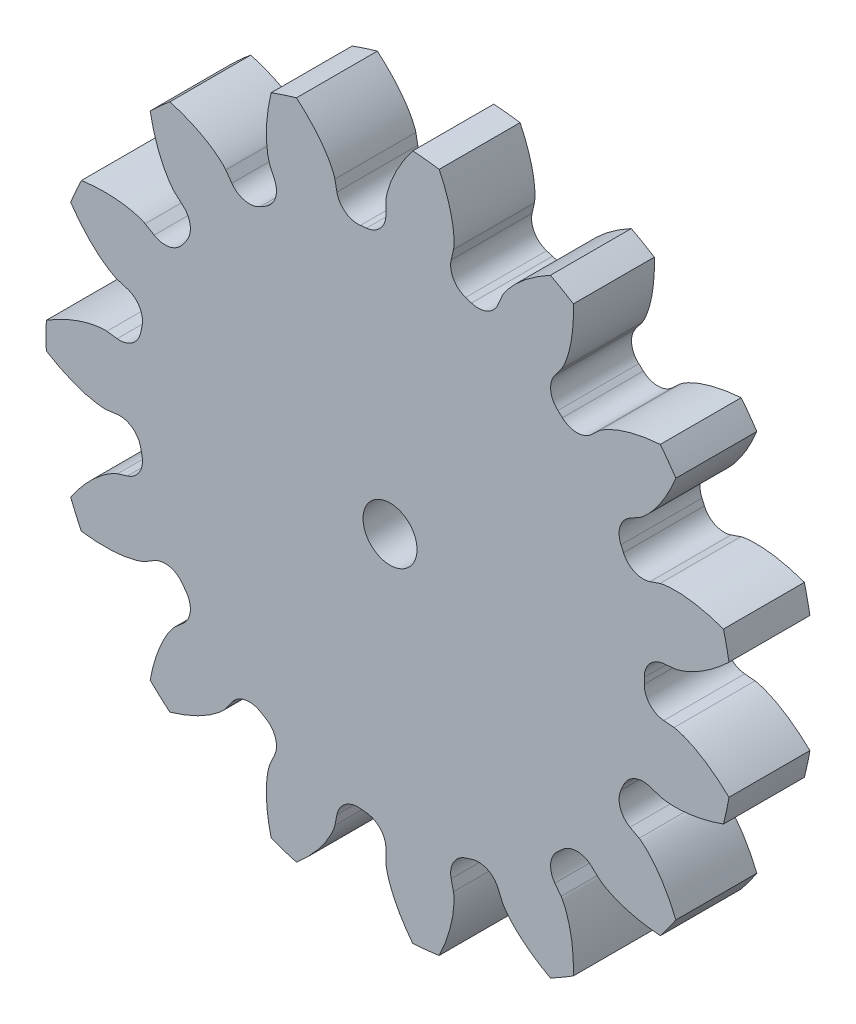
from build123d import *

# Parameters (mm, degrees)
MODEL_R             = 2
BOSS_EXTRUDE3_DEPTH = 6


with BuildPart() as part:
    # Model → Boss-Extrude3 (new body)
    with BuildSketch(Plane.XY):
        with BuildLine():
            Line((-34.011258768, -11.618815397), (-34.774792641, -11.52743848))
            add(Edge.make_bspline(
                [(-34.774792641, -11.52743848), (-34.826134068, -11.521294128), (-34.890522194, -11.517386718), (-34.98103557, -11.518522806), (-35.097797356, -11.525964466), (-35.22773254, -11.536534735), (-35.357743548, -11.548439428), (-35.487878218, -11.564166174), (-35.644167306, -11.588693193), (-35.800499834, -11.617905894), (-35.982808164, -11.655902449), (-36.165028966, -11.698423954), (-36.360077219, -11.750386243), (-36.554881321, -11.806727385), (-36.801193414, -11.884582564), (-37.072735095, -11.979550611), (-37.356271095, -12.087946096), (-37.677019341, -12.222896534), (-38.008768038, -12.375215547), (-38.338592372, -12.538653722), (-38.653580645, -12.706517168), (-38.903824264, -12.848770966), (-39.090405836, -12.959747274), (-39.214314242, -13.035631984), (-39.263800657, -13.066289626)],
                knots=[0, 0, 0, 0, 0, 0, 0.057142857, 0.071428571, 0.1, 0.128571429, 0.142857143, 0.2, 0.214285714, 0.271428571, 0.3, 0.342857143, 0.4, 0.428571429, 0.485714286, 0.571428571, 0.642857143, 0.714285714, 0.785714286, 0.857142857, 0.942857143, 1, 1, 1, 1, 1, 1], degree=5, weights=[1, 1, 1, 1, 1, 1, 1, 1, 1, 1, 1, 1, 1, 1, 1, 1, 1, 1, 1, 1, 1, 1, 1, 1, 1]))
            ThreePointArc((-39.263800657, -13.066289626), (-39.282806436, -14.05063384), (-39.263800657, -15.034978055))
            add(Edge.make_bspline(
                [(-39.263800657, -15.034978055), (-39.102969809, -15.134615388), (-38.89158971, -15.260714719), (-38.62871045, -15.409722251), (-38.300874819, -15.583322699), (-37.906799968, -15.773592135), (-37.625713024, -15.900087405), (-37.317653263, -16.028502931), (-37.008217005, -16.145622994), (-36.73647134, -16.238541398), (-36.490008627, -16.314318325), (-36.269072006, -16.375541947), (-36.086939526, -16.421354833), (-35.943744941, -16.453632457), (-35.787467208, -16.48560511), (-35.657197884, -16.509828379), (-35.52695002, -16.531040649), (-35.396771915, -16.548611412), (-35.266722111, -16.5614978), (-35.123762674, -16.573369014), (-34.993966184, -16.582579543), (-34.890522194, -16.583880962), (-34.826134068, -16.579973552), (-34.774792641, -16.5738292)],
                knots=[-1, -1, -1, -1, -1, -1, -0.814285714, -0.757142857, -0.7, -0.628571429, -0.557142857, -0.5, -0.414285714, -0.357142857, -0.328571429, -0.285714286, -0.257142857, -0.214285714, -0.2, -0.157142857, -0.142857143, -0.114285714, -0.071428571, -0.057142857, 0, 0, 0, 0, 0, 0], degree=5, weights=[1, 1, 1, 1, 1, 1, 1, 1, 1, 1, 1, 1, 1, 1, 1, 1, 1, 1, 1, 1, 1, 1, 1, 1]))
            Line((-34.774792641, -16.5738292), (-34.011258768, -16.482452284))
            ThreePointArc((-34.011258768, -16.482452284), (-32.891020179, -16.773293938), (-32.265948509, -17.747362092))
            ThreePointArc((-32.265948509, -17.747362092), (-32.220106192, -17.969602883), (-32.171591759, -18.191275698))
            ThreePointArc((-32.171591759, -18.191275698), (-32.346433933, -19.335370788), (-33.251526849, -20.056709943))
            Line((-33.251526849, -20.056709943), (-33.986216091, -20.283790181))
            add(Edge.make_bspline(
                [(-33.986216091, -20.283790181), (-34.035617951, -20.299059475), (-34.096028719, -20.321678889), (-34.178254713, -20.359531864), (-34.281895117, -20.413821456), (-34.396297498, -20.476327278), (-34.510226389, -20.540082996), (-34.622713682, -20.607380633), (-34.755514831, -20.693355678), (-34.886449826, -20.783628976), (-35.037542182, -20.892492034), (-35.186714113, -21.00545324), (-35.343764592, -21.132256424), (-35.498810987, -21.262960585), (-35.692161727, -21.434268984), (-35.901600411, -21.631472564), (-36.11653502, -21.845821248), (-36.354663835, -22.099564672), (-36.595777626, -22.373649366), (-36.830610855, -22.657109211), (-37.050090746, -22.938577372), (-37.220839835, -23.170315933), (-37.346152452, -23.347587397), (-37.428483321, -23.467309619), (-37.461221824, -23.515444706)],
                knots=[0, 0, 0, 0, 0, 0, 0.057142857, 0.071428571, 0.1, 0.128571429, 0.142857143, 0.2, 0.214285714, 0.271428571, 0.3, 0.342857143, 0.4, 0.428571429, 0.485714286, 0.571428571, 0.642857143, 0.714285714, 0.785714286, 0.857142857, 0.942857143, 1, 1, 1, 1, 1, 1], degree=5, weights=[1, 1, 1, 1, 1, 1, 1, 1, 1, 1, 1, 1, 1, 1, 1, 1, 1, 1, 1, 1, 1, 1, 1, 1, 1]))
            ThreePointArc((-37.461221824, -23.515444706), (-37.078215606, -24.422418239), (-36.660484101, -25.313931078))
            add(Edge.make_bspline(
                [(-36.660484101, -25.313931078), (-36.473031656, -25.339538512), (-36.228637108, -25.36875995), (-35.927878131, -25.397962477), (-35.557775717, -25.423211614), (-35.120380875, -25.43674671), (-34.812144911, -25.43797753), (-34.478487016, -25.429991758), (-34.148165908, -25.411127194), (-33.86212057, -25.38548346), (-33.606144425, -25.354463711), (-33.379406888, -25.320531254), (-33.194386808, -25.288303454), (-33.050443553, -25.259548046), (-32.894672291, -25.225192637), (-32.76581285, -25.194336387), (-32.638197699, -25.160738181), (-32.512127409, -25.123841666), (-32.388079635, -25.082717948), (-32.252651233, -25.035416), (-32.13032998, -24.991037247), (-32.035299858, -24.950151692), (-31.978067664, -24.920393085), (-31.93366407, -24.893897501)],
                knots=[-1, -1, -1, -1, -1, -1, -0.814285714, -0.757142857, -0.7, -0.628571429, -0.557142857, -0.5, -0.414285714, -0.357142857, -0.328571429, -0.285714286, -0.257142857, -0.214285714, -0.2, -0.157142857, -0.142857143, -0.114285714, -0.071428571, -0.057142857, 0, 0, 0, 0, 0, 0], degree=5, weights=[1, 1, 1, 1, 1, 1, 1, 1, 1, 1, 1, 1, 1, 1, 1, 1, 1, 1, 1, 1, 1, 1, 1, 1]))
            Line((-31.93366407, -24.893897501), (-31.273307508, -24.499863329))
            ThreePointArc((-31.273307508, -24.499863329), (-30.131622677, -24.309918318), (-29.16440208, -24.945534303))
            ThreePointArc((-29.16440208, -24.945534303), (-29.032129567, -25.129915618), (-28.89764697, -25.312691213))
            ThreePointArc((-28.89764697, -25.312691213), (-28.592027848, -26.428988805), (-29.125476303, -27.456099368))
            Line((-29.125476303, -27.456099368), (-29.70428647, -27.962372524))
            add(Edge.make_bspline(
                [(-29.70428647, -27.962372524), (-29.743206733, -27.996415265), (-29.789194571, -28.041650401), (-29.848915562, -28.109675139), (-29.921514216, -28.201425498), (-30.000602584, -28.305059049), (-30.078750018, -28.409641851), (-30.154139858, -28.516874004), (-30.240490543, -28.64943121), (-30.323388155, -28.785156032), (-30.417139296, -28.946062182), (-30.507469174, -29.109931069), (-30.599366424, -29.289649726), (-30.687846183, -29.472116969), (-30.79480347, -29.70725781), (-30.905925306, -29.972598631), (-31.015094378, -30.25583768), (-31.129429127, -30.584499547), (-31.238217247, -30.932958188), (-31.33745457, -31.287426921), (-31.423476013, -31.633831395), (-31.485206504, -31.914985016), (-31.527582475, -32.12789979), (-31.554100052, -32.270758463), (-31.564429859, -32.328048002)],
                knots=[0, 0, 0, 0, 0, 0, 0.057142857, 0.071428571, 0.1, 0.128571429, 0.142857143, 0.2, 0.214285714, 0.271428571, 0.3, 0.342857143, 0.4, 0.428571429, 0.485714286, 0.571428571, 0.642857143, 0.714285714, 0.785714286, 0.857142857, 0.942857143, 1, 1, 1, 1, 1, 1], degree=5, weights=[1, 1, 1, 1, 1, 1, 1, 1, 1, 1, 1, 1, 1, 1, 1, 1, 1, 1, 1, 1, 1, 1, 1, 1, 1]))
            ThreePointArc((-31.564429859, -32.328048002), (-30.845636898, -33.00082689), (-30.10140924, -33.645357684))
            add(Edge.make_bspline(
                [(-30.10140924, -33.645357684), (-29.919747428, -33.592507461), (-29.68459647, -33.519798356), (-29.397961734, -33.424146495), (-29.049586606, -33.296678515), (-28.644501315, -33.131138931), (-28.362413131, -33.00689248), (-28.060849583, -32.863886222), (-27.766759144, -32.712298887), (-27.515873972, -32.57252705), (-27.294644996, -32.440074221), (-27.101311522, -32.316852914), (-26.945395496, -32.212156908), (-26.825592668, -32.127340539), (-26.697262142, -32.032597431), (-26.592093553, -31.951996988), (-26.489176932, -31.869397741), (-26.389013156, -31.784413691), (-26.292416399, -31.696390529), (-26.187935833, -31.598094356), (-26.094240273, -31.507799812), (-26.02405559, -31.431796766), (-25.983875295, -31.381332496), (-25.954087319, -31.339067006)],
                knots=[-1, -1, -1, -1, -1, -1, -0.814285714, -0.757142857, -0.7, -0.628571429, -0.557142857, -0.5, -0.414285714, -0.357142857, -0.328571429, -0.285714286, -0.257142857, -0.214285714, -0.2, -0.157142857, -0.142857143, -0.114285714, -0.071428571, -0.057142857, 0, 0, 0, 0, 0, 0], degree=5, weights=[1, 1, 1, 1, 1, 1, 1, 1, 1, 1, 1, 1, 1, 1, 1, 1, 1, 1, 1, 1, 1, 1, 1, 1]))
            Line((-25.954087319, -31.339067006), (-25.511089717, -30.710507667))
            ThreePointArc((-25.511089717, -30.710507667), (-24.545366321, -30.07261921), (-23.403238027, -30.259879247))
            ThreePointArc((-23.403238027, -30.259879247), (-23.207406436, -30.374519881), (-23.010208939, -30.486794696))
            ThreePointArc((-23.010208939, -30.486794696), (-22.276972843, -31.382276795), (-22.346538754, -32.537562018))
            Line((-22.346538754, -32.537562018), (-22.669388308, -33.235488864))
            add(Edge.make_bspline(
                [(-22.669388308, -33.235488864), (-22.691097308, -33.282418753), (-22.714710501, -33.342448044), (-22.741600188, -33.42888245), (-22.770604125, -33.542229108), (-22.800703382, -33.669071204), (-22.829556957, -33.796397772), (-22.854813757, -33.92502303), (-22.87978316, -34.081242051), (-22.900309639, -34.238950342), (-22.92050914, -34.424077448), (-22.936378109, -34.610519597), (-22.947232261, -34.812078739), (-22.953846429, -35.014758821), (-22.955916376, -35.273074115), (-22.94950739, -35.56067234), (-22.9340346, -35.863827148), (-22.904805766, -36.210578836), (-22.862457761, -36.57315976), (-22.808940145, -36.937346516), (-22.74662925, -37.288790822), (-22.688667379, -37.570745488), (-22.640779515, -37.782488674), (-22.60689867, -37.923782235), (-22.593033664, -37.980320345)],
                knots=[0, 0, 0, 0, 0, 0, 0.057142857, 0.071428571, 0.1, 0.128571429, 0.142857143, 0.2, 0.214285714, 0.271428571, 0.3, 0.342857143, 0.4, 0.428571429, 0.485714286, 0.571428571, 0.642857143, 0.714285714, 0.785714286, 0.857142857, 0.942857143, 1, 1, 1, 1, 1, 1], degree=5, weights=[1, 1, 1, 1, 1, 1, 1, 1, 1, 1, 1, 1, 1, 1, 1, 1, 1, 1, 1, 1, 1, 1, 1, 1, 1]))
            ThreePointArc((-22.593033664, -37.980320345), (-21.662739793, -38.302575006), (-20.720699704, -38.588678526))
            add(Edge.make_bspline(
                [(-20.720699704, -38.588678526), (-20.576239504, -38.466508929), (-20.390991871, -38.304441345), (-20.168043127, -38.100474172), (-19.901632509, -37.842329447), (-19.598899697, -37.526338481), (-19.391734902, -37.298098099), (-19.174408778, -37.044798436), (-18.967399917, -36.786699157), (-18.795055235, -36.556967037), (-18.646825928, -36.345983426), (-18.520325633, -36.154779353), (-18.420472957, -35.995718031), (-18.345525553, -35.869506222), (-18.266825277, -35.730757359), (-18.203532144, -35.614349271), (-18.143109273, -35.497031144), (-18.086171238, -35.378654073), (-18.033727955, -35.258951473), (-17.978260864, -35.126657375), (-17.929391809, -35.006059787), (-17.896188135, -34.908080868), (-17.880007277, -34.845636664), (-17.86998553, -34.794909357)],
                knots=[-1, -1, -1, -1, -1, -1, -0.814285714, -0.757142857, -0.7, -0.628571429, -0.557142857, -0.5, -0.414285714, -0.357142857, -0.328571429, -0.285714286, -0.257142857, -0.214285714, -0.2, -0.157142857, -0.142857143, -0.114285714, -0.071428571, -0.057142857, 0, 0, 0, 0, 0, 0], degree=5, weights=[1, 1, 1, 1, 1, 1, 1, 1, 1, 1, 1, 1, 1, 1, 1, 1, 1, 1, 1, 1, 1, 1, 1, 1]))
            Line((-17.86998553, -34.794909357), (-17.720945199, -34.040508471))
            ThreePointArc((-17.720945199, -34.040508471), (-17.098165587, -33.064973276), (-15.978613953, -32.771498403))
            ThreePointArc((-15.978613953, -32.771498403), (-15.753084346, -32.79657595), (-15.527269187, -32.81893665))
            ThreePointArc((-15.527269187, -32.81893665), (-14.493199299, -33.338766265), (-14.086854087, -34.422466838))
            Line((-14.086854087, -34.422466838), (-14.097919409, -35.191369482))
            add(Edge.make_bspline(
                [(-14.097919409, -35.191369482), (-14.098663462, -35.243071914), (-14.095819074, -35.307515751), (-14.085227985, -35.397414531), (-14.065622162, -35.51275882), (-14.041527872, -35.640877311), (-14.016098544, -35.768931726), (-13.986855174, -35.896709612), (-13.946125858, -36.04957876), (-13.900731989, -36.202001324), (-13.843887174, -36.379339228), (-13.782551345, -36.556117097), (-13.710485617, -36.744665318), (-13.634090544, -36.93251301), (-13.530915239, -37.169337697), (-13.408083603, -37.42946498), (-13.270644337, -37.700117327), (-13.10290585, -38.005002318), (-12.916744075, -38.319011989), (-12.719725201, -38.62994557), (-12.519856089, -38.925661796), (-12.352223991, -39.159664983), (-12.222352537, -39.333624259), (-12.133931576, -39.448921769), (-12.098269142, -39.494932496)],
                knots=[0, 0, 0, 0, 0, 0, 0.057142857, 0.071428571, 0.1, 0.128571429, 0.142857143, 0.2, 0.214285714, 0.271428571, 0.3, 0.342857143, 0.4, 0.428571429, 0.485714286, 0.571428571, 0.642857143, 0.714285714, 0.785714286, 0.857142857, 0.942857143, 1, 1, 1, 1, 1, 1], degree=5, weights=[1, 1, 1, 1, 1, 1, 1, 1, 1, 1, 1, 1, 1, 1, 1, 1, 1, 1, 1, 1, 1, 1, 1, 1, 1]))
            ThreePointArc((-12.098269142, -39.494932496), (-11.117330623, -39.410942172), (-10.140365394, -39.28914852))
            add(Edge.make_bspline(
                [(-10.140365394, -39.28914852), (-10.058085285, -39.118783783), (-9.954771977, -38.895380677), (-9.834059089, -38.618365969), (-9.695677797, -38.274180068), (-9.547642716, -37.862375428), (-9.451221986, -37.569605951), (-9.355710947, -37.249810697), (-9.271577377, -36.929827183), (-9.207573147, -36.649857551), (-9.157973702, -36.396824141), (-9.120179635, -36.170698223), (-9.093655745, -35.984774733), (-9.076522851, -35.838990652), (-9.061060819, -35.680226973), (-9.050587099, -35.548139256), (-9.043105641, -35.416387618), (-9.039238451, -35.285085998), (-9.040016561, -35.154401626), (-9.043153709, -35.010984456), (-9.047561065, -34.880936242), (-9.057079616, -34.777922894), (-9.067696012, -34.714295928), (-9.079173346, -34.663878015)],
                knots=[-1, -1, -1, -1, -1, -1, -0.814285714, -0.757142857, -0.7, -0.628571429, -0.557142857, -0.5, -0.414285714, -0.357142857, -0.328571429, -0.285714286, -0.257142857, -0.214285714, -0.2, -0.157142857, -0.142857143, -0.114285714, -0.071428571, -0.057142857, 0, 0, 0, 0, 0, 0], degree=5, weights=[1, 1, 1, 1, 1, 1, 1, 1, 1, 1, 1, 1, 1, 1, 1, 1, 1, 1, 1, 1, 1, 1, 1, 1]))
            Line((-9.079173346, -34.663878015), (-9.249860712, -33.914078348))
            ThreePointArc((-9.249860712, -33.914078348), (-9.077709137, -32.769575313), (-8.174314811, -32.046110003))
            ThreePointArc((-8.174314811, -32.046110003), (-7.958083306, -31.977288327), (-7.742695977, -31.905868543))
            ThreePointArc((-7.742695977, -31.905868543), (-6.586592375, -31.960162412), (-5.77459682, -32.78489666))
            Line((-5.77459682, -32.78489666), (-5.471964614, -33.49182485))
            add(Edge.make_bspline(
                [(-5.471964614, -33.49182485), (-5.451615066, -33.539360005), (-5.422804919, -33.597075463), (-5.37656435, -33.674894302), (-5.31173879, -33.772292145), (-5.237617076, -33.879534181), (-5.162301806, -33.98617467), (-5.08361471, -34.091011227), (-4.984229145, -34.214098038), (-4.880763939, -34.334879629), (-4.756703793, -34.473764996), (-4.628768688, -34.610312087), (-4.486243899, -34.753247685), (-4.340048987, -34.893782415), (-4.149468378, -35.068167355), (-3.931452797, -35.255845325), (-3.695811553, -35.447196962), (-3.418566922, -35.657497872), (-3.120780439, -35.868641165), (-2.81432666, -36.07255833), (-2.511458516, -36.261414453), (-2.263141303, -36.407004885), (-2.073742215, -36.513101112), (-1.946069925, -36.582466584), (-1.894776422, -36.609994256)],
                knots=[0, 0, 0, 0, 0, 0, 0.057142857, 0.071428571, 0.1, 0.128571429, 0.142857143, 0.2, 0.214285714, 0.271428571, 0.3, 0.342857143, 0.4, 0.428571429, 0.485714286, 0.571428571, 0.642857143, 0.714285714, 0.785714286, 0.857142857, 0.942857143, 1, 1, 1, 1, 1, 1], degree=5, weights=[1, 1, 1, 1, 1, 1, 1, 1, 1, 1, 1, 1, 1, 1, 1, 1, 1, 1, 1, 1, 1, 1, 1, 1, 1]))
            ThreePointArc((-1.894776422, -36.609994256), (-1.032806436, -36.134281637), (-0.18984223, -35.625650042))
            add(Edge.make_bspline(
                [(-0.18984223, -35.625650042), (-0.183969192, -35.436547774), (-0.180454018, -35.190437574), (-0.182849339, -34.888273691), (-0.196424757, -34.517559482), (-0.228684018, -34.081145932), (-0.259679372, -33.774469862), (-0.302498145, -33.443474521), (-0.355787324, -33.116934829), (-0.411190458, -32.835136978), (-0.468797071, -32.583805544), (-0.52624417, -32.361857006), (-0.577635286, -32.181219208), (-0.621279337, -32.041070248), (-0.671729073, -31.889743436), (-0.715885769, -31.764815256), (-0.762639336, -31.641411163), (-0.812511662, -31.519888236), (-0.866376624, -31.400818607), (-0.927575569, -31.271076496), (-0.984497263, -31.154064174), (-1.035092196, -31.063828341), (-1.070670175, -31.010020293), (-1.101662053, -30.96862949)],
                knots=[-1, -1, -1, -1, -1, -1, -0.814285714, -0.757142857, -0.7, -0.628571429, -0.557142857, -0.5, -0.414285714, -0.357142857, -0.328571429, -0.285714286, -0.257142857, -0.214285714, -0.2, -0.157142857, -0.142857143, -0.114285714, -0.071428571, -0.057142857, 0, 0, 0, 0, 0, 0], degree=5, weights=[1, 1, 1, 1, 1, 1, 1, 1, 1, 1, 1, 1, 1, 1, 1, 1, 1, 1, 1, 1, 1, 1, 1, 1]))
            Line((-1.101662053, -30.96862949), (-1.562563721, -30.353078216))
            ThreePointArc((-1.562563721, -30.353078216), (-1.870806754, -29.237502314), (-1.339774823, -28.209140291))
            ThreePointArc((-1.339774823, -28.209140291), (-1.170229811, -28.058319285), (-1.002512738, -27.905468146))
            ThreePointArc((-1.002512738, -27.905468146), (0.075723762, -27.484838365), (1.152968252, -27.908002245))
            Line((1.152968252, -27.908002245), (1.716970128, -28.430721674))
            add(Edge.make_bspline(
                [(1.716970128, -28.430721674), (1.754894655, -28.465870293), (1.804689026, -28.506877845), (1.878583661, -28.559161157), (1.977420028, -28.621771584), (2.088752849, -28.689594042), (2.200931366, -28.756381496), (2.315456475, -28.820149531), (2.456313623, -28.892171177), (2.59996009, -28.96042756), (2.769784442, -29.03684585), (2.942197681, -29.109551929), (3.130537699, -29.182160041), (3.321254021, -29.251082077), (3.566286816, -29.33287453), (3.841789468, -29.415651962), (4.134888178, -29.494616451), (4.473700837, -29.573970342), (4.831622041, -29.645738664), (5.194522081, -29.707380283), (5.548020604, -29.756721364), (5.83408663, -29.788725132), (6.05026453, -29.808613309), (6.195112449, -29.820052823), (6.253167909, -29.824337655)],
                knots=[0, 0, 0, 0, 0, 0, 0.057142857, 0.071428571, 0.1, 0.128571429, 0.142857143, 0.2, 0.214285714, 0.271428571, 0.3, 0.342857143, 0.4, 0.428571429, 0.485714286, 0.571428571, 0.642857143, 0.714285714, 0.785714286, 0.857142857, 0.942857143, 1, 1, 1, 1, 1, 1], degree=5, weights=[1, 1, 1, 1, 1, 1, 1, 1, 1, 1, 1, 1, 1, 1, 1, 1, 1, 1, 1, 1, 1, 1, 1, 1, 1]))
            ThreePointArc((6.253167909, -29.824337655), (6.84712692, -29.039157774), (7.410333934, -28.231635259))
            add(Edge.make_bspline(
                [(7.410333934, -28.231635259), (7.3387844, -28.056492962), (7.241893634, -27.830230356), (7.116804276, -27.555164178), (6.953619463, -27.222021517), (6.746643779, -26.836458924), (6.593591719, -26.568903339), (6.419846889, -26.283940012), (6.238349144, -26.007305823), (6.07311835, -25.772405161), (5.918266387, -25.566233191), (5.775511248, -25.386838952), (5.655091115, -25.242720763), (5.558216573, -25.132439952), (5.450578286, -25.014715786), (5.359426269, -24.918548361), (5.266521793, -24.824829501), (5.171533329, -24.734097685), (5.073895257, -24.647231021), (4.965216367, -24.553597559), (4.865622614, -24.469853622), (4.782699623, -24.4079979), (4.728311817, -24.373312669), (4.683164171, -24.348105822)],
                knots=[-1, -1, -1, -1, -1, -1, -0.814285714, -0.757142857, -0.7, -0.628571429, -0.557142857, -0.5, -0.414285714, -0.357142857, -0.328571429, -0.285714286, -0.257142857, -0.214285714, -0.2, -0.157142857, -0.142857143, -0.114285714, -0.071428571, -0.057142857, 0, 0, 0, 0, 0, 0], degree=5, weights=[1, 1, 1, 1, 1, 1, 1, 1, 1, 1, 1, 1, 1, 1, 1, 1, 1, 1, 1, 1, 1, 1, 1, 1]))
            Line((4.683164171, -24.348105822), (4.011742287, -23.973237349))
            ThreePointArc((4.011742287, -23.973237349), (3.276402667, -23.079481787), (3.343251958, -21.924036187))
            ThreePointArc((3.343251958, -21.924036187), (3.436794604, -21.717294173), (3.527841615, -21.50944103))
            ThreePointArc((3.527841615, -21.50944103), (4.341774126, -20.68661831), (5.498002194, -20.635042943))
            Line((5.498002194, -20.635042943), (6.225852692, -20.883170673))
            add(Edge.make_bspline(
                [(6.225852692, -20.883170673), (6.274794702, -20.899855239), (6.336963397, -20.917064307), (6.425735044, -20.934771834), (6.541492514, -20.951768933), (6.670785985, -20.968444693), (6.800431065, -20.983830955), (6.930991754, -20.995504395), (7.088965004, -21.004007679), (7.247954954, -21.007936706), (7.434179338, -21.008674501), (7.621258896, -21.004968027), (7.822848444, -20.994694051), (8.025109591, -20.980086148), (8.282226176, -20.955143456), (8.567578986, -20.918707378), (8.867455733, -20.871631043), (9.209252634, -20.806316907), (9.56542073, -20.726300862), (9.922018318, -20.635008538), (10.265024114, -20.536303056), (10.539375538, -20.449186419), (10.744953127, -20.379427699), (10.881931155, -20.330963258), (10.936710255, -20.311264364)],
                knots=[0, 0, 0, 0, 0, 0, 0.057142857, 0.071428571, 0.1, 0.128571429, 0.142857143, 0.2, 0.214285714, 0.271428571, 0.3, 0.342857143, 0.4, 0.428571429, 0.485714286, 0.571428571, 0.642857143, 0.714285714, 0.785714286, 0.857142857, 0.942857143, 1, 1, 1, 1, 1, 1], degree=5, weights=[1, 1, 1, 1, 1, 1, 1, 1, 1, 1, 1, 1, 1, 1, 1, 1, 1, 1, 1, 1, 1, 1, 1, 1, 1]))
            ThreePointArc((10.936710255, -20.311264364), (11.159957382, -19.352381956), (11.346023595, -18.3855965))
            add(Edge.make_bspline(
                [(11.346023595, -18.3855965), (11.209423053, -18.254697868), (11.028879641, -18.087405717), (10.802725333, -17.886998685), (10.51814726, -17.649030963), (10.172243129, -17.380986603), (9.923598454, -17.198814295), (9.648969628, -17.009155731), (9.370645925, -16.830259607), (9.124157377, -16.682872593), (8.898835375, -16.557509094), (8.695455856, -16.451688048), (8.526828442, -16.369008812), (8.393473897, -16.307664704), (8.247258697, -16.243898762), (8.12487237, -16.193120314), (8.001881014, -16.145291529), (7.87820078, -16.10103918), (7.753672107, -16.061395515), (7.616304841, -16.020060777), (7.491259692, -15.984065313), (7.390346782, -15.961285118), (7.326553294, -15.951720097), (7.275056319, -15.947055698)],
                knots=[-1, -1, -1, -1, -1, -1, -0.814285714, -0.757142857, -0.7, -0.628571429, -0.557142857, -0.5, -0.414285714, -0.357142857, -0.328571429, -0.285714286, -0.257142857, -0.214285714, -0.2, -0.157142857, -0.142857143, -0.114285714, -0.071428571, -0.057142857, 0, 0, 0, 0, 0, 0], degree=5, weights=[1, 1, 1, 1, 1, 1, 1, 1, 1, 1, 1, 1, 1, 1, 1, 1, 1, 1, 1, 1, 1, 1, 1, 1]))
            Line((7.275056319, -15.947055698), (6.509209163, -15.877688191))
            ThreePointArc((6.509209163, -15.877688191), (5.473919855, -15.360291426), (5.065027657, -14.27754929))
            ThreePointArc((5.065027657, -14.27754929), (5.066393564, -14.05063384), (5.065027657, -13.82371839))
            ThreePointArc((5.065027657, -13.82371839), (5.473919855, -12.740976255), (6.509209163, -12.223579489))
            Line((6.509209163, -12.223579489), (7.275056319, -12.154211982))
            add(Edge.make_bspline(
                [(7.275056319, -12.154211982), (7.326553294, -12.149547583), (7.390346782, -12.139982562), (7.478646017, -12.120052511), (7.59130907, -12.088497329), (7.716207176, -12.051143002), (7.840902007, -12.012467647), (7.964923147, -11.970028048), (8.11269749, -11.913542675), (8.259540115, -11.852464982), (8.429964643, -11.77739471), (8.599362765, -11.697916566), (8.779345178, -11.606536966), (8.958178361, -11.510924962), (9.182920942, -11.383559943), (9.428783818, -11.234210485), (9.683587188, -11.069233252), (9.969268541, -10.870544495), (10.26209883, -10.652579585), (10.550735004, -10.424138592), (10.823939254, -10.194453621), (11.039138223, -10.003279835), (11.198569268, -9.855936135), (11.303992659, -9.755947682), (11.346023595, -9.71567118)],
                knots=[0, 0, 0, 0, 0, 0, 0.057142857, 0.071428571, 0.1, 0.128571429, 0.142857143, 0.2, 0.214285714, 0.271428571, 0.3, 0.342857143, 0.4, 0.428571429, 0.485714286, 0.571428571, 0.642857143, 0.714285714, 0.785714286, 0.857142857, 0.942857143, 1, 1, 1, 1, 1, 1], degree=5, weights=[1, 1, 1, 1, 1, 1, 1, 1, 1, 1, 1, 1, 1, 1, 1, 1, 1, 1, 1, 1, 1, 1, 1, 1, 1]))
            ThreePointArc((11.346023595, -9.71567118), (11.159957382, -8.748885724), (10.936710255, -7.790003316))
            add(Edge.make_bspline(
                [(10.936710255, -7.790003316), (10.75867818, -7.725981911), (10.525699719, -7.646586548), (10.237584594, -7.555490858), (9.880819395, -7.453844857), (9.455796785, -7.349666034), (9.154552419, -7.28437625), (8.826525414, -7.222816137), (8.499500451, -7.172590844), (8.214374258, -7.138202032), (7.957542438, -7.115323492), (7.728704705, -7.101373059), (7.541027222, -7.094428766), (7.394250886, -7.092628314), (7.234740709, -7.093846308), (7.102281781, -7.097236891), (6.970469867, -7.103568213), (6.839483299, -7.113446964), (6.709596164, -7.127881048), (6.56729257, -7.145992187), (6.438417468, -7.163969139), (6.336963397, -7.184203373), (6.274794702, -7.201412441), (6.225852692, -7.218097007)],
                knots=[-1, -1, -1, -1, -1, -1, -0.814285714, -0.757142857, -0.7, -0.628571429, -0.557142857, -0.5, -0.414285714, -0.357142857, -0.328571429, -0.285714286, -0.257142857, -0.214285714, -0.2, -0.157142857, -0.142857143, -0.114285714, -0.071428571, -0.057142857, 0, 0, 0, 0, 0, 0], degree=5, weights=[1, 1, 1, 1, 1, 1, 1, 1, 1, 1, 1, 1, 1, 1, 1, 1, 1, 1, 1, 1, 1, 1, 1, 1]))
            Line((6.225852692, -7.218097007), (5.498002194, -7.466224737))
            ThreePointArc((5.498002194, -7.466224737), (4.341774126, -7.41464937), (3.527841615, -6.59182665))
            ThreePointArc((3.527841615, -6.59182665), (3.436794604, -6.383973507), (3.343251958, -6.177231493))
            ThreePointArc((3.343251958, -6.177231493), (3.276402667, -5.021785893), (4.011742287, -4.128030331))
            Line((4.011742287, -4.128030331), (4.683164171, -3.753161859))
            add(Edge.make_bspline(
                [(4.683164171, -3.753161859), (4.728311817, -3.727955011), (4.782699623, -3.693269781), (4.855258706, -3.639148239), (4.945346878, -3.564496953), (5.044253602, -3.479571441), (5.142437314, -3.393521789), (5.238474524, -3.304307345), (5.350498432, -3.192600149), (5.459803309, -3.077076622), (5.584960032, -2.939178616), (5.707386243, -2.797671296), (5.834640928, -2.640986434), (5.959124264, -2.480902515), (6.112632808, -2.273137736), (6.276493825, -2.036698777), (6.442166, -1.782346708), (6.622334904, -1.484638422), (6.801194368, -1.16641276), (6.971961311, -0.840322619), (7.128124519, -0.519372778), (7.246961175, -0.257197528), (7.332678601, -0.057745913), (7.388318693, 0.076477641), (7.410333934, 0.130367578)],
                knots=[0, 0, 0, 0, 0, 0, 0.057142857, 0.071428571, 0.1, 0.128571429, 0.142857143, 0.2, 0.214285714, 0.271428571, 0.3, 0.342857143, 0.4, 0.428571429, 0.485714286, 0.571428571, 0.642857143, 0.714285714, 0.785714286, 0.857142857, 0.942857143, 1, 1, 1, 1, 1, 1], degree=5, weights=[1, 1, 1, 1, 1, 1, 1, 1, 1, 1, 1, 1, 1, 1, 1, 1, 1, 1, 1, 1, 1, 1, 1, 1, 1]))
            ThreePointArc((7.410333934, 0.130367578), (6.84712692, 0.937890093), (6.253167909, 1.723069974))
            add(Edge.make_bspline(
                [(6.253167909, 1.723069974), (6.064487664, 1.70914427), (5.819358246, 1.686914666), (5.519100027, 1.652947741), (5.151835647, 1.600696504), (4.721184827, 1.522996325), (4.419428658, 1.460114388), (4.094722324, 1.382931747), (3.775541687, 1.295801799), (3.501078759, 1.211246273), (3.257145675, 1.127683946), (3.042417852, 1.047351609), (2.868141441, 0.977360227), (2.733322277, 0.919305708), (2.588097882, 0.853314381), (2.468469704, 0.79634103), (2.350628709, 0.736944343), (2.234984575, 0.674642619), (2.122197644, 0.60862657), (1.999563306, 0.534201135), (1.889141927, 0.465360146), (1.804689026, 0.405610165), (1.754894655, 0.364602613), (1.716970128, 0.329453994)],
                knots=[-1, -1, -1, -1, -1, -1, -0.814285714, -0.757142857, -0.7, -0.628571429, -0.557142857, -0.5, -0.414285714, -0.357142857, -0.328571429, -0.285714286, -0.257142857, -0.214285714, -0.2, -0.157142857, -0.142857143, -0.114285714, -0.071428571, -0.057142857, 0, 0, 0, 0, 0, 0], degree=5, weights=[1, 1, 1, 1, 1, 1, 1, 1, 1, 1, 1, 1, 1, 1, 1, 1, 1, 1, 1, 1, 1, 1, 1, 1]))
            Line((1.716970128, 0.329453994), (1.152968252, -0.193265435))
            ThreePointArc((1.152968252, -0.193265435), (0.075723762, -0.616429315), (-1.002512738, -0.195799535))
            ThreePointArc((-1.002512738, -0.195799535), (-1.170229811, -0.042948396), (-1.339774823, 0.10787261))
            ThreePointArc((-1.339774823, 0.10787261), (-1.870806754, 1.136234633), (-1.562563721, 2.251810536))
            Line((-1.562563721, 2.251810536), (-1.101662053, 2.86736181))
            add(Edge.make_bspline(
                [(-1.101662053, 2.86736181), (-1.070670175, 2.908752613), (-1.035092196, 2.962560661), (-0.990819389, 3.041515588), (-0.938883162, 3.146355091), (-0.883069692, 3.264167396), (-0.828373954, 3.382712578), (-0.776926381, 3.503275881), (-0.720022858, 3.650889711), (-0.667155535, 3.800884002), (-0.608907352, 3.977765925), (-0.554621655, 4.156834521), (-0.502098191, 4.351732407), (-0.453489, 4.54860828), (-0.397757516, 4.800848399), (-0.344231417, 5.083494416), (-0.296336661, 5.383241538), (-0.252833045, 5.728492886), (-0.218870832, 6.091955192), (-0.195500276, 6.459310531), (-0.183380148, 6.8160301), (-0.181453741, 7.103874331), (-0.184271257, 7.320946866), (-0.188035141, 7.466197048), (-0.18984223, 7.524382361)],
                knots=[0, 0, 0, 0, 0, 0, 0.057142857, 0.071428571, 0.1, 0.128571429, 0.142857143, 0.2, 0.214285714, 0.271428571, 0.3, 0.342857143, 0.4, 0.428571429, 0.485714286, 0.571428571, 0.642857143, 0.714285714, 0.785714286, 0.857142857, 0.942857143, 1, 1, 1, 1, 1, 1], degree=5, weights=[1, 1, 1, 1, 1, 1, 1, 1, 1, 1, 1, 1, 1, 1, 1, 1, 1, 1, 1, 1, 1, 1, 1, 1, 1]))
            ThreePointArc((-0.18984223, 7.524382361), (-1.032806436, 8.033013956), (-1.894776422, 8.508726576))
            add(Edge.make_bspline(
                [(-1.894776422, 8.508726576), (-2.061480308, 8.419261642), (-2.276375581, 8.299250772), (-2.536859519, 8.146094421), (-2.851119732, 7.948980661), (-3.212935323, 7.702836546), (-3.463026913, 7.522655747), (-3.728267901, 7.320075931), (-3.98441498, 7.110656303), (-4.20075751, 6.921776855), (-4.38961361, 6.746222348), (-4.553103133, 6.585497433), (-4.683844497, 6.450672521), (-4.783395031, 6.342801185), (-4.889223027, 6.223447025), (-4.975335656, 6.122742115), (-5.058829953, 6.020550291), (-5.139135732, 5.916598127), (-5.215320574, 5.810414887), (-5.297081065, 5.69254399), (-5.369955862, 5.584742196), (-5.422804919, 5.495807783), (-5.451615066, 5.438092325), (-5.471964614, 5.390557169)],
                knots=[-1, -1, -1, -1, -1, -1, -0.814285714, -0.757142857, -0.7, -0.628571429, -0.557142857, -0.5, -0.414285714, -0.357142857, -0.328571429, -0.285714286, -0.257142857, -0.214285714, -0.2, -0.157142857, -0.142857143, -0.114285714, -0.071428571, -0.057142857, 0, 0, 0, 0, 0, 0], degree=5, weights=[1, 1, 1, 1, 1, 1, 1, 1, 1, 1, 1, 1, 1, 1, 1, 1, 1, 1, 1, 1, 1, 1, 1, 1]))
            Line((-5.471964614, 5.390557169), (-5.77459682, 4.68362898))
            ThreePointArc((-5.77459682, 4.68362898), (-6.586592375, 3.858894731), (-7.742695977, 3.804600862))
            ThreePointArc((-7.742695977, 3.804600862), (-7.958083306, 3.876020647), (-8.174314811, 3.944842323))
            ThreePointArc((-8.174314811, 3.944842323), (-9.077709137, 4.668307633), (-9.249860712, 5.812810668))
            Line((-9.249860712, 5.812810668), (-9.079173346, 6.562610335))
            add(Edge.make_bspline(
                [(-9.079173346, 6.562610335), (-9.067696012, 6.613028247), (-9.057079616, 6.676655214), (-9.048748256, 6.766791501), (-9.04394422, 6.883691519), (-9.040874659, 7.014019799), (-9.039124286, 7.144562972), (-9.041162102, 7.275628643), (-9.049218101, 7.433625335), (-9.061929573, 7.592155016), (-9.080661569, 7.777436363), (-9.103902877, 7.963103648), (-9.135192416, 8.162514944), (-9.170862343, 8.362141142), (-9.222544398, 8.615241994), (-9.288608365, 8.895223005), (-9.366772467, 9.188536179), (-9.46745631, 9.521633494), (-9.584263723, 9.867486509), (-9.712330535, 10.212587973), (-9.846349167, 10.543397215), (-9.961666103, 10.807139544), (-10.052531387, 11.004299186), (-10.115048437, 11.135460921), (-10.140365394, 11.18788084)],
                knots=[0, 0, 0, 0, 0, 0, 0.057142857, 0.071428571, 0.1, 0.128571429, 0.142857143, 0.2, 0.214285714, 0.271428571, 0.3, 0.342857143, 0.4, 0.428571429, 0.485714286, 0.571428571, 0.642857143, 0.714285714, 0.785714286, 0.857142857, 0.942857143, 1, 1, 1, 1, 1, 1], degree=5, weights=[1, 1, 1, 1, 1, 1, 1, 1, 1, 1, 1, 1, 1, 1, 1, 1, 1, 1, 1, 1, 1, 1, 1, 1, 1]))
            ThreePointArc((-10.140365394, 11.18788084), (-11.117330623, 11.309674492), (-12.098269142, 11.393664816))
            add(Edge.make_bspline(
                [(-12.098269142, 11.393664816), (-12.214172053, 11.244129953), (-12.361675835, 11.047088786), (-12.537345454, 10.801225135), (-12.744263055, 10.49333161), (-12.974682213, 10.121304114), (-13.129866116, 9.854979349), (-13.289779181, 9.56203025), (-13.438602545, 9.266531496), (-13.559417088, 9.005987101), (-13.66054127, 8.768795382), (-13.744523668, 8.555468685), (-13.809123615, 8.379122697), (-13.856192328, 8.240086477), (-13.904325303, 8.088006903), (-13.942032727, 7.960983228), (-13.976743403, 7.833666162), (-14.007825229, 7.706037831), (-14.034234931, 7.578047448), (-14.060984443, 7.437112038), (-14.083711943, 7.308989349), (-14.095819074, 7.206248071), (-14.098663462, 7.141804234), (-14.097919409, 7.090101802)],
                knots=[-1, -1, -1, -1, -1, -1, -0.814285714, -0.757142857, -0.7, -0.628571429, -0.557142857, -0.5, -0.414285714, -0.357142857, -0.328571429, -0.285714286, -0.257142857, -0.214285714, -0.2, -0.157142857, -0.142857143, -0.114285714, -0.071428571, -0.057142857, 0, 0, 0, 0, 0, 0], degree=5, weights=[1, 1, 1, 1, 1, 1, 1, 1, 1, 1, 1, 1, 1, 1, 1, 1, 1, 1, 1, 1, 1, 1, 1, 1]))
            Line((-14.097919409, 7.090101802), (-14.086854087, 6.321199158))
            ThreePointArc((-14.086854087, 6.321199158), (-14.493199299, 5.237498585), (-15.527269187, 4.717668969))
            ThreePointArc((-15.527269187, 4.717668969), (-15.753084346, 4.69530827), (-15.978613953, 4.670230723))
            ThreePointArc((-15.978613953, 4.670230723), (-17.098165587, 4.963705595), (-17.720945199, 5.93924079))
            Line((-17.720945199, 5.93924079), (-17.86998553, 6.693641677))
            add(Edge.make_bspline(
                [(-17.86998553, 6.693641677), (-17.880007277, 6.744368984), (-17.896188135, 6.806813187), (-17.92523879, 6.892545452), (-17.968397606, 7.001292911), (-18.018602709, 7.121602222), (-18.070100356, 7.241571285), (-18.125271205, 7.360476879), (-18.19689377, 7.501537369), (-18.272986108, 7.641191218), (-18.365459351, 7.802835162), (-18.46220903, 7.962997575), (-18.571901328, 8.132442257), (-18.685682717, 8.300301597), (-18.835842015, 8.510499745), (-19.010072989, 8.739404489), (-19.200780664, 8.975567203), (-19.428242816, 9.238914933), (-19.675622791, 9.50735753), (-19.932983057, 9.770533939), (-20.18996741, 10.01823293), (-20.402588343, 10.212269914), (-20.565789961, 10.355425969), (-20.676250412, 10.4498202), (-20.720699704, 10.487410846)],
                knots=[0, 0, 0, 0, 0, 0, 0.057142857, 0.071428571, 0.1, 0.128571429, 0.142857143, 0.2, 0.214285714, 0.271428571, 0.3, 0.342857143, 0.4, 0.428571429, 0.485714286, 0.571428571, 0.642857143, 0.714285714, 0.785714286, 0.857142857, 0.942857143, 1, 1, 1, 1, 1, 1], degree=5, weights=[1, 1, 1, 1, 1, 1, 1, 1, 1, 1, 1, 1, 1, 1, 1, 1, 1, 1, 1, 1, 1, 1, 1, 1, 1]))
            ThreePointArc((-20.720699704, 10.487410846), (-21.662739793, 10.201307325), (-22.593033664, 9.879052664))
            add(Edge.make_bspline(
                [(-22.593033664, 9.879052664), (-22.638094934, 9.695303809), (-22.69270248, 9.455302552), (-22.753182907, 9.15924366), (-22.816979963, 8.793807958), (-22.876161123, 8.360224014), (-22.909604632, 8.053805255), (-22.936539353, 7.721140432), (-22.95230609, 7.390656974), (-22.956702714, 7.103498122), (-22.952609688, 6.845681795), (-22.942563642, 6.616639442), (-22.929852254, 6.429264199), (-22.916300538, 6.283103722), (-22.898415863, 6.124594673), (-22.881198126, 5.993215781), (-22.86112339, 5.86278775), (-22.837606932, 5.73355135), (-22.809675016, 5.605884524), (-22.776788316, 5.466253613), (-22.745438728, 5.339963605), (-22.714710501, 5.241180364), (-22.691097308, 5.181151073), (-22.669388308, 5.134221184)],
                knots=[-1, -1, -1, -1, -1, -1, -0.814285714, -0.757142857, -0.7, -0.628571429, -0.557142857, -0.5, -0.414285714, -0.357142857, -0.328571429, -0.285714286, -0.257142857, -0.214285714, -0.2, -0.157142857, -0.142857143, -0.114285714, -0.071428571, -0.057142857, 0, 0, 0, 0, 0, 0], degree=5, weights=[1, 1, 1, 1, 1, 1, 1, 1, 1, 1, 1, 1, 1, 1, 1, 1, 1, 1, 1, 1, 1, 1, 1, 1]))
            Line((-22.669388308, 5.134221184), (-22.346538754, 4.436294338))
            ThreePointArc((-22.346538754, 4.436294338), (-22.276972843, 3.281009115), (-23.010208939, 2.385527016))
            ThreePointArc((-23.010208939, 2.385527016), (-23.207406436, 2.273252201), (-23.403238027, 2.158611566))
            ThreePointArc((-23.403238027, 2.158611566), (-24.545366321, 1.971351529), (-25.511089717, 2.609239987))
            Line((-25.511089717, 2.609239987), (-25.954087319, 3.237799326))
            add(Edge.make_bspline(
                [(-25.954087319, 3.237799326), (-25.983875295, 3.280064815), (-26.02405559, 3.330529086), (-26.085465138, 3.397033441), (-26.169124254, 3.478824916), (-26.263923103, 3.568312685), (-26.359764358, 3.656963899), (-26.458528699, 3.743149558), (-26.581333638, 3.842883206), (-26.707649785, 3.939513803), (-26.857874812, 4.049570638), (-27.011403964, 4.156534643), (-27.180532226, 4.266714185), (-27.352751241, 4.373782263), (-27.575423875, 4.504732537), (-27.827695737, 4.642981305), (-28.097971896, 4.78115888), (-28.412882084, 4.929221811), (-28.748060378, 5.073837824), (-29.090214168, 5.209583587), (-29.425729313, 5.331342923), (-29.698890152, 5.422123803), (-29.906209062, 5.486523289), (-30.045513298, 5.527828397), (-30.10140924, 5.544090004)],
                knots=[0, 0, 0, 0, 0, 0, 0.057142857, 0.071428571, 0.1, 0.128571429, 0.142857143, 0.2, 0.214285714, 0.271428571, 0.3, 0.342857143, 0.4, 0.428571429, 0.485714286, 0.571428571, 0.642857143, 0.714285714, 0.785714286, 0.857142857, 0.942857143, 1, 1, 1, 1, 1, 1], degree=5, weights=[1, 1, 1, 1, 1, 1, 1, 1, 1, 1, 1, 1, 1, 1, 1, 1, 1, 1, 1, 1, 1, 1, 1, 1, 1]))
            ThreePointArc((-30.10140924, 5.544090004), (-30.845636898, 4.89955921), (-31.564429859, 4.226780322))
            add(Edge.make_bspline(
                [(-31.564429859, 4.226780322), (-31.530857985, 4.040589319), (-31.483127156, 3.799126372), (-31.417960775, 3.504063509), (-31.327606195, 3.144272784), (-31.205316397, 2.724102995), (-31.111236825, 2.430572829), (-31.000535944, 2.115713053), (-30.880519842, 1.807388481), (-30.767738331, 1.543267548), (-30.659135818, 1.309405397), (-30.556798381, 1.104250891), (-30.468973573, 0.938245276), (-30.397144643, 0.810233016), (-30.31633474, 0.672702147), (-30.247168946, 0.559684641), (-30.175779902, 0.448697837), (-30.101731369, 0.340199516), (-30.024287518, 0.234931001), (-29.937451015, 0.120748042), (-29.857444967, 0.018127406), (-29.789194571, -0.05961728), (-29.743206733, -0.104852415), (-29.70428647, -0.138895156)],
                knots=[-1, -1, -1, -1, -1, -1, -0.814285714, -0.757142857, -0.7, -0.628571429, -0.557142857, -0.5, -0.414285714, -0.357142857, -0.328571429, -0.285714286, -0.257142857, -0.214285714, -0.2, -0.157142857, -0.142857143, -0.114285714, -0.071428571, -0.057142857, 0, 0, 0, 0, 0, 0], degree=5, weights=[1, 1, 1, 1, 1, 1, 1, 1, 1, 1, 1, 1, 1, 1, 1, 1, 1, 1, 1, 1, 1, 1, 1, 1]))
            Line((-29.70428647, -0.138895156), (-29.125476303, -0.645168312))
            ThreePointArc((-29.125476303, -0.645168312), (-28.592027848, -1.672278875), (-28.89764697, -2.788576467))
            ThreePointArc((-28.89764697, -2.788576467), (-29.032129567, -2.971352063), (-29.16440208, -3.155733377))
            ThreePointArc((-29.16440208, -3.155733377), (-30.131622677, -3.791349362), (-31.273307508, -3.601404351))
            Line((-31.273307508, -3.601404351), (-31.93366407, -3.20737018))
            add(Edge.make_bspline(
                [(-31.93366407, -3.20737018), (-31.978067664, -3.180874595), (-32.035299858, -3.151115988), (-32.118450029, -3.11533875), (-32.228144025, -3.074645748), (-32.351145038, -3.031452768), (-32.474758078, -2.989448006), (-32.600038659, -2.950884564), (-32.752791882, -2.909722612), (-32.907490629, -2.872823574), (-33.089492167, -2.833383676), (-33.273254207, -2.798113127), (-33.47257462, -2.766249768), (-33.67345303, -2.738485996), (-33.930136877, -2.709426087), (-34.216829531, -2.685737764), (-34.519940972, -2.669437486), (-34.867848363, -2.662260781), (-35.232869602, -2.666476772), (-35.600655419, -2.681633331), (-35.956687739, -2.706866947), (-36.243156494, -2.735039009), (-36.458745372, -2.760531349), (-36.602806426, -2.779457392), (-36.660484101, -2.787336603)],
                knots=[0, 0, 0, 0, 0, 0, 0.057142857, 0.071428571, 0.1, 0.128571429, 0.142857143, 0.2, 0.214285714, 0.271428571, 0.3, 0.342857143, 0.4, 0.428571429, 0.485714286, 0.571428571, 0.642857143, 0.714285714, 0.785714286, 0.857142857, 0.942857143, 1, 1, 1, 1, 1, 1], degree=5, weights=[1, 1, 1, 1, 1, 1, 1, 1, 1, 1, 1, 1, 1, 1, 1, 1, 1, 1, 1, 1, 1, 1, 1, 1, 1]))
            ThreePointArc((-36.660484101, -2.787336603), (-37.078215606, -3.678849442), (-37.461221824, -4.585822975))
            add(Edge.make_bspline(
                [(-37.461221824, -4.585822975), (-37.354821688, -4.742262008), (-37.213005577, -4.94343551), (-37.033460247, -5.186483292), (-36.804577159, -5.478417956), (-36.52196142, -5.812522417), (-36.316625981, -6.042409957), (-36.087430685, -6.285022571), (-35.852383619, -6.517876137), (-35.641924921, -6.713290242), (-35.447591282, -6.882761326), (-35.270657525, -7.028554907), (-35.122905005, -7.144487015), (-35.005218735, -7.232216576), (-34.875456372, -7.324988929), (-34.766301913, -7.400103294), (-34.655942376, -7.472458246), (-34.544165433, -7.541458142), (-34.430600392, -7.606126464), (-34.304828905, -7.675118199), (-34.190000171, -7.736325424), (-34.096028719, -7.779588791), (-34.035617951, -7.802208205), (-33.986216091, -7.817477499)],
                knots=[-1, -1, -1, -1, -1, -1, -0.814285714, -0.757142857, -0.7, -0.628571429, -0.557142857, -0.5, -0.414285714, -0.357142857, -0.328571429, -0.285714286, -0.257142857, -0.214285714, -0.2, -0.157142857, -0.142857143, -0.114285714, -0.071428571, -0.057142857, 0, 0, 0, 0, 0, 0], degree=5, weights=[1, 1, 1, 1, 1, 1, 1, 1, 1, 1, 1, 1, 1, 1, 1, 1, 1, 1, 1, 1, 1, 1, 1, 1]))
            Line((-33.986216091, -7.817477499), (-33.251526849, -8.044557737))
            ThreePointArc((-33.251526849, -8.044557737), (-32.346433933, -8.765896892), (-32.171591759, -9.909991983))
            ThreePointArc((-32.171591759, -9.909991983), (-32.220106192, -10.131664798), (-32.265948509, -10.353905588))
            ThreePointArc((-32.265948509, -10.353905588), (-32.891020179, -11.327973742), (-34.011258768, -11.618815397))
        make_face()
        with Locations((-13.782806436, -14.05063384)):
            Circle(MODEL_R, mode=Mode.SUBTRACT)
    extrude(amount=BOSS_EXTRUDE3_DEPTH)


solid = part.part
